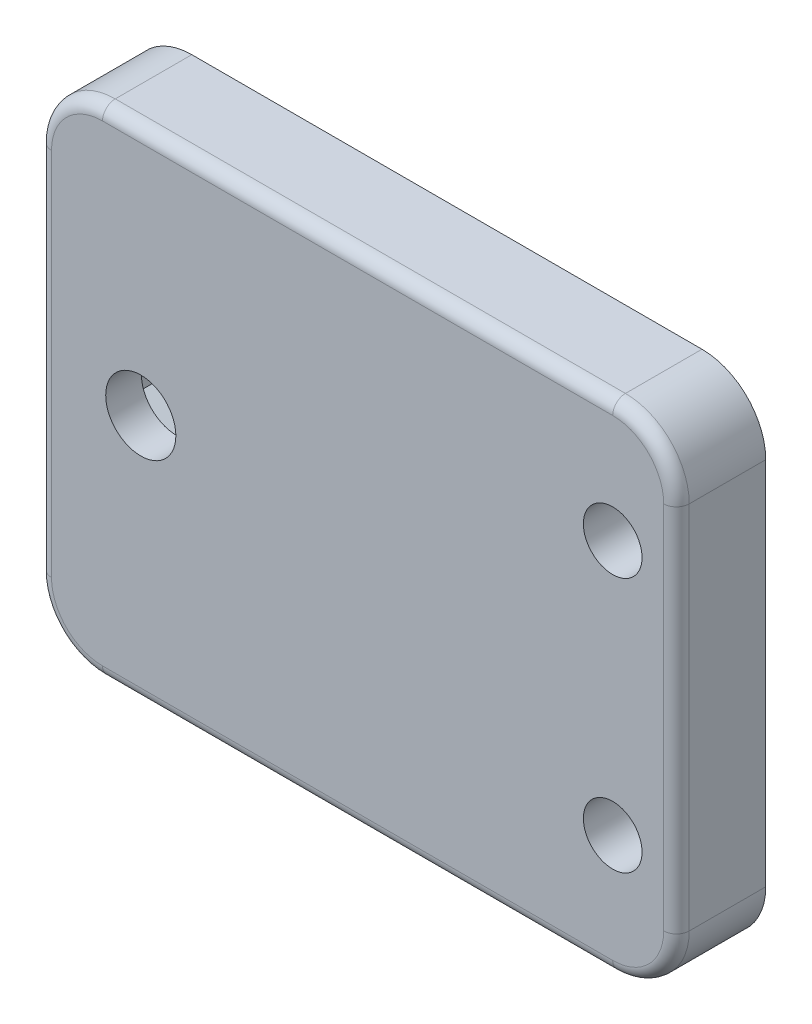
from build123d import *

# Parameters (mm, degrees)
SKETCH1_W           = 50
SKETCH1_H           = 39
SKETCH1_R           = 2.75
SKETCH1_R_2         = 2.3
BOSS_EXTRUDE1_DEPTH = 7
CUT_EXTRUDE1_DEPTH  = 4.2
FILLET1_R           = 5
SKETCH3_W           = 8
SKETCH3_H           = 5
BOSS_EXTRUDE2_DEPTH = 4
FILLET2_R           = 1
FILLET3_R           = 1
FILLET4_R           = 1


with BuildPart() as part:
    # Sketch1 → Boss-Extrude1 (new body)
    with BuildSketch(Plane.XY):
        Rectangle(SKETCH1_W, SKETCH1_H)
        with Locations((-17, 0)):
            Circle(SKETCH1_R, mode=Mode.SUBTRACT)
        with Locations((20, 10)):
            Circle(SKETCH1_R_2, mode=Mode.SUBTRACT)
        with Locations((20, -10)):
            Circle(SKETCH1_R_2, mode=Mode.SUBTRACT)
    extrude(amount=BOSS_EXTRUDE1_DEPTH)

    # Sketch2 → Cut-Extrude1 (cut)
    with BuildSketch(Plane(origin=(0, 0, 0), x_dir=(-1, 0, 0), z_dir=(0, 0, -1))):
        Polygon((17, 4.67653718), (12.95, 2.33826859), (12.95, -2.33826859), (17, -4.67653718), (21.05, -2.33826859), (21.05, 2.33826859), align=None)
    extrude(amount=-CUT_EXTRUDE1_DEPTH, mode=Mode.SUBTRACT)

    # Fillet1
    fillet1_edges = [part.edges().sort_by_distance(p)[0] for p in [
        (25, -19.5, 3.5),
        (-25, -19.5, 3.5),
        (-25, 19.5, 3.5),
        (25, 19.5, 3.5),
    ]]
    fillet(fillet1_edges, radius=FILLET1_R)

    # Sketch3 → Boss-Extrude2 (add)
    with BuildSketch(Plane(origin=(0, 0, 0), x_dir=(-1, 0, 0), z_dir=(0, 0, -1))):
        with Locations((-12.5, 10)):
            Rectangle(SKETCH3_W, SKETCH3_H)
    boss_extrude2 = extrude(amount=BOSS_EXTRUDE2_DEPTH)

    # Mirror1: Boss-Extrude2 across plane
    add(boss_extrude2.mirror(Plane.ZX))

    # Fillet2
    fillet2_edges = [part.edges().sort_by_distance(p)[0] for p in [
        (8.5, 7.5, -2),
        (8.5, 12.5, -2),
        (16.5, 12.5, -2),
        (16.5, 7.5, -2),
    ]]
    fillet(fillet2_edges, radius=FILLET2_R)

    # Fillet3
    fillet3_edges = [part.edges().sort_by_distance(p)[0] for p in [
        (8.5, -12.5, -2),
        (8.5, -7.5, -2),
        (16.5, -7.5, -2),
        (16.5, -12.5, -2),
    ]]
    fillet(fillet3_edges, radius=FILLET3_R)

    # Fillet4
    fillet4_edges = [part.edges().sort_by_distance(p)[0] for p in [
        (25, 0, 7),
        (0, -19.5, 7),
        (0, 19.5, 7),
        (-25, 0, 7),
        (23.535533906, 18.035533906, 7),
        (-23.535533906, 18.035533906, 7),
        (-23.535533906, -18.035533906, 7),
        (23.535533906, -18.035533906, 7),
    ]]
    fillet(fillet4_edges, radius=FILLET4_R)


solid = part.part
